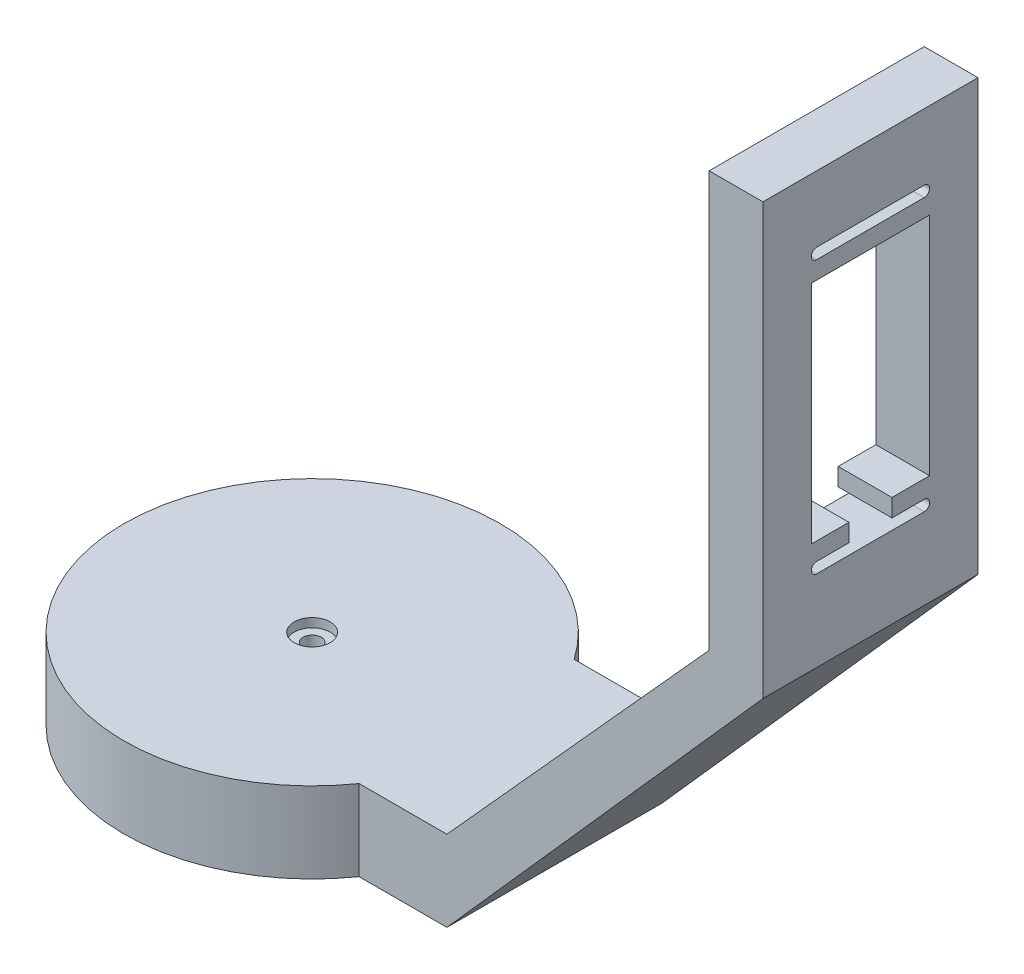
from build123d import *

# Parameters (mm, degrees)
EXTRUDE_1_DEPTH        = 15
EXTRUDE_2_DEPTH        = 40
F_1_4_BASE_D           = 3.4
F_1_4_BASE_CBORE_D     = 6.7
F_1_4_BASE_CBORE_DEPTH = 1.65
SKETCH_11_W            = 22
SKETCH_11_H            = 42
CUT_EXTRUDE_1_DEPTH    = 32
CUT_EXTRUDE_3_DEPTH    = 2
CUT_EXTRUDE_4_DEPTH    = 3.5
CUT_EXTRUDE_5_DEPTH    = 20
SKETCH_22_W            = 8
SKETCH_22_H            = 3.3
CUT_EXTRUDE_6_DEPTH    = 20


with BuildPart() as part:
    # 草图1 → 凸台-拉伸1 (new body)
    with BuildSketch(Plane(origin=(0, 0, 0), x_dir=(1, 0, 0), z_dir=(0, 1, 0))):
        with BuildLine():
            Line((45.055476805, 20), (28.722813233, 20))
            ThreePointArc((28.722813233, 20), (33.393850206, 10.480971731), (35, 0))
            ThreePointArc((35, 0), (33.393850206, -10.480971731), (28.722813233, -20))
            Line((28.722813233, -20), (45.055476805, -20))
            Line((45.055476805, -20), (45.055476805, 20))
        make_face()
        with BuildLine():
            Line((0.055476805, -20), (0.055476805, 20))
            Line((0.055476805, 20), (28.722813233, 20))
            ThreePointArc((28.722813233, 20), (-35, 0), (28.722813233, -20))
            Line((28.722813233, -20), (0.055476805, -20))
        make_face()
        with BuildLine():
            Line((28.722813233, 20), (0.055476805, 20))
            Line((0.055476805, 20), (0.055476805, -20))
            Line((0.055476805, -20), (28.722813233, -20))
            ThreePointArc((28.722813233, -20), (33.393850206, -10.480971731), (35, 0))
            ThreePointArc((35, 0), (33.393850206, 10.480971731), (28.722813233, 20))
        make_face()
    extrude(amount=EXTRUDE_1_DEPTH)

    # 草图2 → 凸台-拉伸2 (add)
    with BuildSketch(Plane.XY.offset(20)):
        Polygon((45.055476805, 0), (103.81943921, 66.228799241), (103.81943921, 146.228799241), (93.81943921, 146.228799241), (93.81943921, 69.009357532), (45.055476805, 15), align=None)
    extrude(amount=-EXTRUDE_2_DEPTH)

    # 1/4 六角头螺钉的柱形沉头孔base (through all)
    with Locations(Plane(origin=(0, 15, 0), x_dir=(1, 0, 0), z_dir=(0, 1, 0))):
        with Locations((0, 0)):
            CounterBoreHole(F_1_4_BASE_D / 2, F_1_4_BASE_CBORE_D / 2, F_1_4_BASE_CBORE_DEPTH)

    # 草图11 → 切除-拉伸1 (cut)
    with BuildSketch(Plane(origin=(103.81943921, 0, 0), x_dir=(0, 0, -1), z_dir=(1, 0, 0))):
        with Locations((0, 107.618799241)):
            Rectangle(SKETCH_11_W, SKETCH_11_H)
    extrude(amount=-CUT_EXTRUDE_1_DEPTH, mode=Mode.SUBTRACT)

    # 草图19 → 切除-拉伸3 (cut)
    with BuildSketch(Plane.XZ):
        with BuildLine():
            Line((-29.938978194, 2.983548036), (0, 6))
            Line((0, 6), (29.925496738, 2.977040035))
            ThreePointArc((29.925496738, 2.977040035), (32.999946297, -0.039985046), (29.889613095, -3.020003134))
            Line((29.889613095, -3.020003134), (0, -6))
            Line((0, -6), (-30.07371717, -4.263466486))
            ThreePointArc((-30.07371717, -4.263466486), (-33.623512821, -0.572707651), (-29.938978194, 2.983548036))
        make_face()
    extrude(amount=-CUT_EXTRUDE_3_DEPTH, mode=Mode.SUBTRACT)

    # 草图20 → 切除-拉伸4 (cut)
    with BuildSketch(Plane.XZ):
        Polygon((0, 6), (-10.447108364, 4.947418969), (-10.447108364, -5.396757185), (0, -6), (10.446834114, -4.958449786), (10.446834114, 4.944700515), align=None)
    extrude(amount=-CUT_EXTRUDE_4_DEPTH, mode=Mode.SUBTRACT)

    # 草图21 → 切除-拉伸5 (cut)
    with BuildSketch(Plane(origin=(103.81943921, 0, 0), x_dir=(0, 0, -1), z_dir=(1, 0, 0))):
        with BuildLine():
            Line((-10, 133.918799241), (10, 133.918799241))
            ThreePointArc((10, 133.918799241), (11, 132.918799241), (10, 131.918799241))
            Line((10, 131.918799241), (-10, 131.918799241))
            ThreePointArc((-10, 131.918799241), (-11, 132.918799241), (-10, 133.918799241))
        make_face()
        with BuildLine():
            Line((-10, 83.318799241), (10, 83.318799241))
            ThreePointArc((10, 83.318799241), (11, 82.318799241), (10, 81.318799241))
            Line((10, 81.318799241), (-10, 81.318799241))
            ThreePointArc((-10, 81.318799241), (-11, 82.318799241), (-10, 83.318799241))
        make_face()
    extrude(amount=-CUT_EXTRUDE_5_DEPTH, mode=Mode.SUBTRACT)

    # 草图22 → 切除-拉伸6 (cut)
    with BuildSketch(Plane(origin=(103.81943921, 0, 0), x_dir=(0, 0, -1), z_dir=(1, 0, 0))):
        with Locations((0, 84.968799241)):
            Rectangle(SKETCH_22_W, SKETCH_22_H)
    extrude(amount=-CUT_EXTRUDE_6_DEPTH, mode=Mode.SUBTRACT)


solid = part.part
